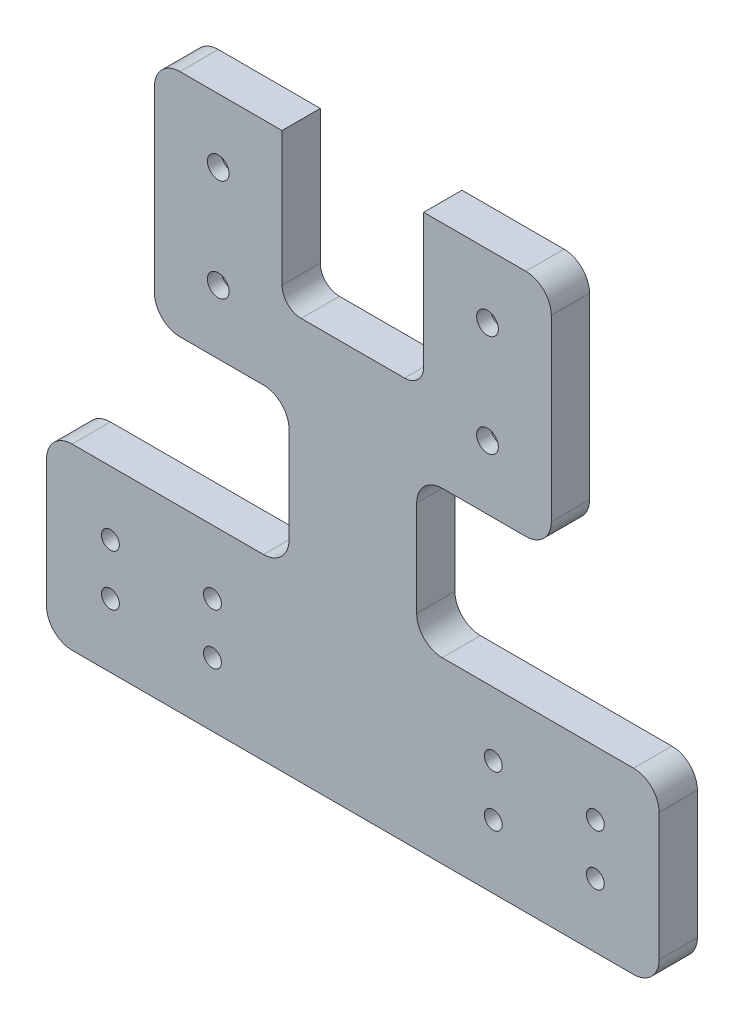
from build123d import *

# Parameters (mm, degrees)
SKETCH1_W           = 100
SKETCH1_H           = 100
BOSS_EXTRUDE1_DEPTH = 6
SKETCH2_R           = 2.9
CUT_EXTRUDE1_DEPTH  = 3.8
SKETCH3_R           = 1.7
CUT_EXTRUDE2_DEPTH  = 6
SKETCH4_R           = 2.3
CUT_EXTRUDE3_DEPTH  = 2.5
SKETCH5_R           = 1.4
CUT_EXTRUDE4_DEPTH  = 6
SKETCH6_W           = 100
SKETCH6_H           = 100
CUT_EXTRUDE5_DEPTH  = 10
CUT_EXTRUDE6_REACH  = 8


with BuildPart() as part:
    # Sketch1 → Boss-Extrude1 (new body)
    with BuildSketch(Plane.XY):
        with Locations((0, -30)):
            Rectangle(SKETCH1_W, SKETCH1_H)
    extrude(amount=BOSS_EXTRUDE1_DEPTH)

    # Sketch2 → Cut-Extrude1 (cut)
    with BuildSketch(Plane.XY):
        with Locations((21.1, -8)):
            Circle(SKETCH2_R)
        with Locations((-21.1, 8)):
            Circle(SKETCH2_R)
        with Locations((-21.1, -8)):
            Circle(SKETCH2_R)
        with Locations((21.1, 8)):
            Circle(SKETCH2_R)
    extrude(amount=CUT_EXTRUDE1_DEPTH, mode=Mode.SUBTRACT)

    # Sketch3 → Cut-Extrude2 (cut)
    with BuildSketch(Plane(origin=(0, 0, 0), x_dir=(-1, 0, 0), z_dir=(0, 0, -1))):
        with Locations((-21.1, 8)):
            Circle(SKETCH3_R)
        with Locations((21.1, 8)):
            Circle(SKETCH3_R)
        with Locations((21.1, -8)):
            Circle(SKETCH3_R)
        with Locations((-21.1, -8)):
            Circle(SKETCH3_R)
    extrude(amount=-CUT_EXTRUDE2_DEPTH, mode=Mode.SUBTRACT)

    # Sketch4 → Cut-Extrude3 (cut)
    with BuildSketch(Plane(origin=(0, 0, 0), x_dir=(-1, 0, 0), z_dir=(0, 0, -1))):
        with Locations((-38, -59)):
            Circle(SKETCH4_R)
        with Locations((-38, -51)):
            Circle(SKETCH4_R)
        with Locations((-22, -51)):
            Circle(SKETCH4_R)
        with Locations((-22, -59)):
            Circle(SKETCH4_R)
        with Locations((37.999999976, -59)):
            Circle(SKETCH4_R)
        with Locations((22, -51)):
            Circle(SKETCH4_R)
        with Locations((22, -59)):
            Circle(SKETCH4_R)
        with Locations((37.999999976, -51)):
            Circle(SKETCH4_R)
    extrude(amount=-CUT_EXTRUDE3_DEPTH, mode=Mode.SUBTRACT)

    # Sketch5 → Cut-Extrude4 (cut)
    with BuildSketch(Plane(origin=(0, 0, 0), x_dir=(-1, 0, 0), z_dir=(0, 0, -1))):
        with Locations((-38.000000024, -59)):
            Circle(SKETCH5_R)
        with Locations((-38.000000024, -51)):
            Circle(SKETCH5_R)
        with Locations((-22, -51)):
            Circle(SKETCH5_R)
        with Locations((-22, -59)):
            Circle(SKETCH5_R)
        with Locations((37.999999976, -59)):
            Circle(SKETCH5_R)
        with Locations((22, -51)):
            Circle(SKETCH5_R)
        with Locations((22, -59)):
            Circle(SKETCH5_R)
        with Locations((37.999999976, -51)):
            Circle(SKETCH5_R)
    extrude(amount=-CUT_EXTRUDE4_DEPTH, mode=Mode.SUBTRACT)

    # Sketch6 → Cut-Extrude5 (cut)
    with BuildSketch(Plane.XY.offset(6)):
        with Locations((0, -30)):
            Rectangle(SKETCH6_W, SKETCH6_H)
        with BuildLine():
            Line((-31.1, -14), (-31.1, 14))
            ThreePointArc((-31.1, 14), (-29.928427125, 16.828427125), (-27.1, 18))
            Line((-27.1, 18), (27.1, 18))
            ThreePointArc((27.1, 18), (29.928427125, 16.828427125), (31.1, 14))
            Line((31.1, 14), (31.1, -14))
            ThreePointArc((31.1, -14), (29.928427125, -16.828427125), (27.1, -18))
            Line((27.1, -18), (14, -18))
            ThreePointArc((14, -18), (11.171572875, -19.171572875), (10, -22))
            Line((10, -22), (10, -37))
            ThreePointArc((10, -37), (11.171572875, -39.828427125), (14, -41))
            Line((14, -41), (44.000000024, -41))
            ThreePointArc((44.000000024, -41), (46.828427149, -42.171572875), (48.000000024, -45))
            Line((48.000000024, -45), (48.000000024, -65))
            ThreePointArc((48.000000024, -65), (46.828427149, -67.828427125), (44.000000024, -69))
            Line((44.000000024, -69), (-43.999999976, -69))
            ThreePointArc((-43.999999976, -69), (-46.8284271, -67.828427125), (-47.999999976, -65))
            Line((-47.999999976, -65), (-47.999999976, -45))
            ThreePointArc((-47.999999976, -45), (-46.8284271, -42.171572875), (-43.999999976, -41))
            Line((-43.999999976, -41), (-14, -41))
            ThreePointArc((-14, -41), (-11.171572875, -39.828427125), (-10, -37))
            Line((-10, -37), (-10, -22))
            ThreePointArc((-10, -22), (-11.171572875, -19.171572875), (-14, -18))
            Line((-14, -18), (-27.1, -18))
            ThreePointArc((-27.1, -18), (-29.928427125, -16.828427125), (-31.1, -14))
        make_face(mode=Mode.SUBTRACT)
    extrude(amount=-CUT_EXTRUDE5_DEPTH, mode=Mode.SUBTRACT)

    # Sketch7 → Cut-Extrude6 (cut, up to next)
    with BuildSketch(Plane.XY, mode=Mode.PRIVATE) as cut_extrude6_sk1:
        with BuildLine():
            Line((-11.1, 18), (-11.1, -3))
            ThreePointArc((-11.1, -3), (-10.221320344, -5.121320344), (-8.1, -6))
            Line((-8.1, -6), (8.1, -6))
            ThreePointArc((8.1, -6), (10.221320344, -5.121320344), (11.1, -3))
            Line((11.1, -3), (11.1, 18))
            Line((11.1, 18), (-11.1, 18))
        make_face()
    cut_extrude6_tool1 = extrude(cut_extrude6_sk1.sketch, amount=CUT_EXTRUDE6_REACH, mode=Mode.PRIVATE) & part.part
    add(cut_extrude6_tool1.solids().sort_by_distance((0, 6.082742, 0))[0], mode=Mode.SUBTRACT)


solid = part.part
